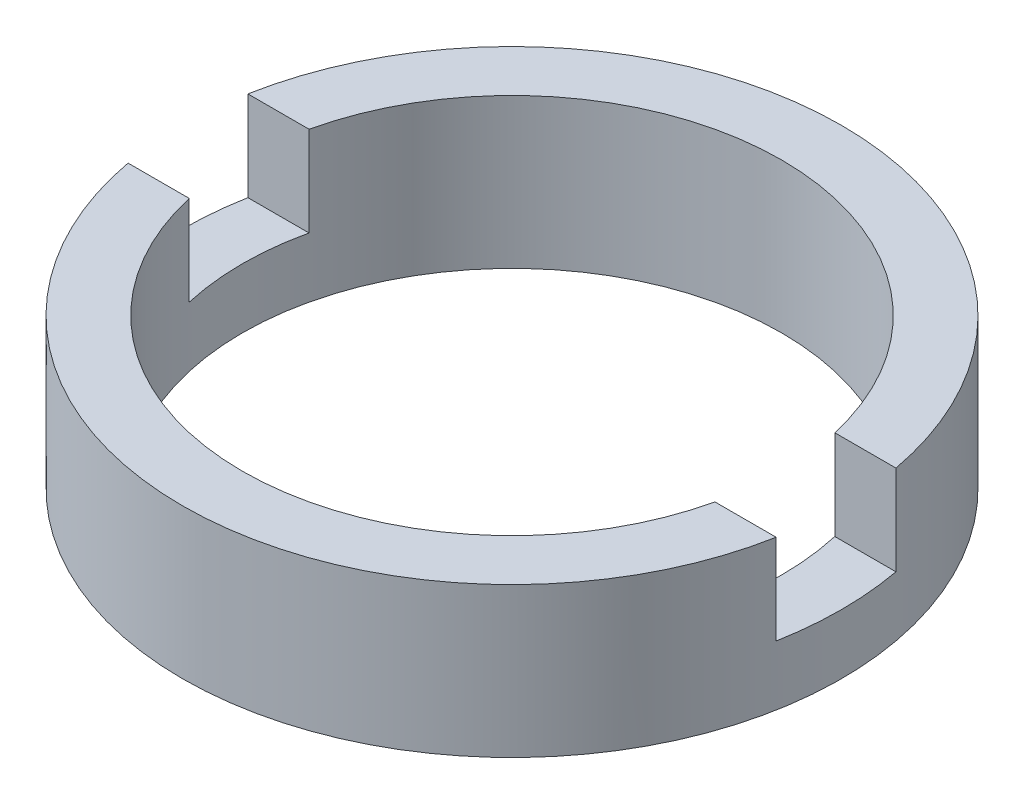
from build123d import *

# Parameters (mm, degrees)
SKETCH_1_W          = 1
SKETCH_1_H          = 2.5
SKETCH_2_W          = 53.705080546
SKETCH_2_H          = 2
CUT_EXTRUDE_1_DEPTH = 1.5


with BuildPart() as part:
    # 草图1 → 旋转1 (revolve)
    with BuildSketch(Plane.XY, mode=Mode.PRIVATE) as revolve_1_sk:
        with Locations((5, -3.214249787)):
            Rectangle(SKETCH_1_W, SKETCH_1_H)
    revolve(revolve_1_sk.sketch.rotate(Axis((0, 56.260842627, 0), (0, -1, 0)), 90), axis=Axis((0, 56.260842627, 0), (0, -1, 0)))  # turned: the seam where the file's is

    # 草图2 → 切除-拉伸1 (cut)
    with BuildSketch(Plane(origin=(0, -1.964249787, 0), x_dir=(1, 0, 0), z_dir=(0, 1, 0))):
        Rectangle(SKETCH_2_W, SKETCH_2_H)
    extrude(amount=-CUT_EXTRUDE_1_DEPTH, mode=Mode.SUBTRACT)


solid = part.part
